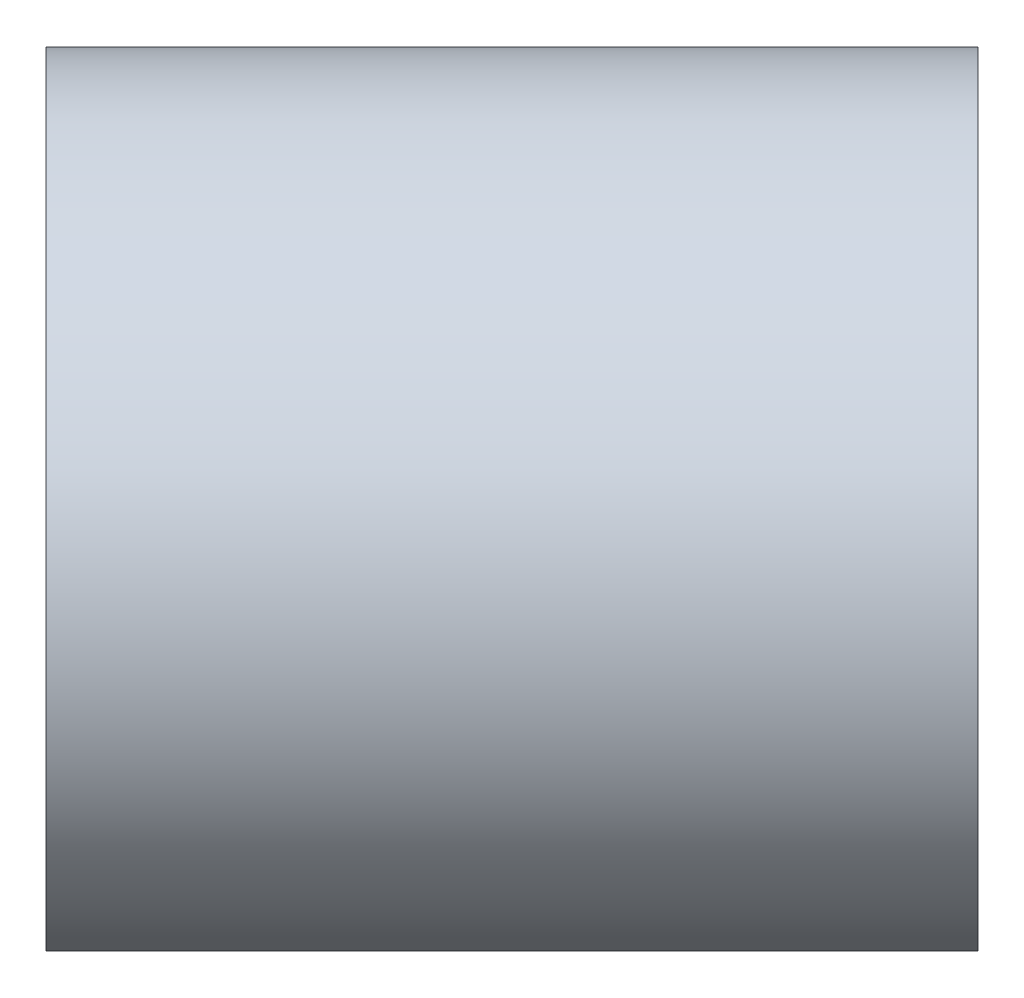
from build123d import *

# Parameters (mm, degrees)
SKETCH1_R           = 49
BOSS_EXTRUDE1_DEPTH = 101


with BuildPart() as part:
    # Sketch1 → Boss-Extrude1 (new body)
    with BuildSketch(Plane(origin=(155.855354978, 0, -155.855354978), x_dir=(-0.707106781, 0, -0.707106781), z_dir=(0.707106781, 0, -0.707106781))):
        with Locations((558.507949545, -7.5)):
            Circle(SKETCH1_R)
    extrude(amount=-BOSS_EXTRUDE1_DEPTH)


solid = part.part
